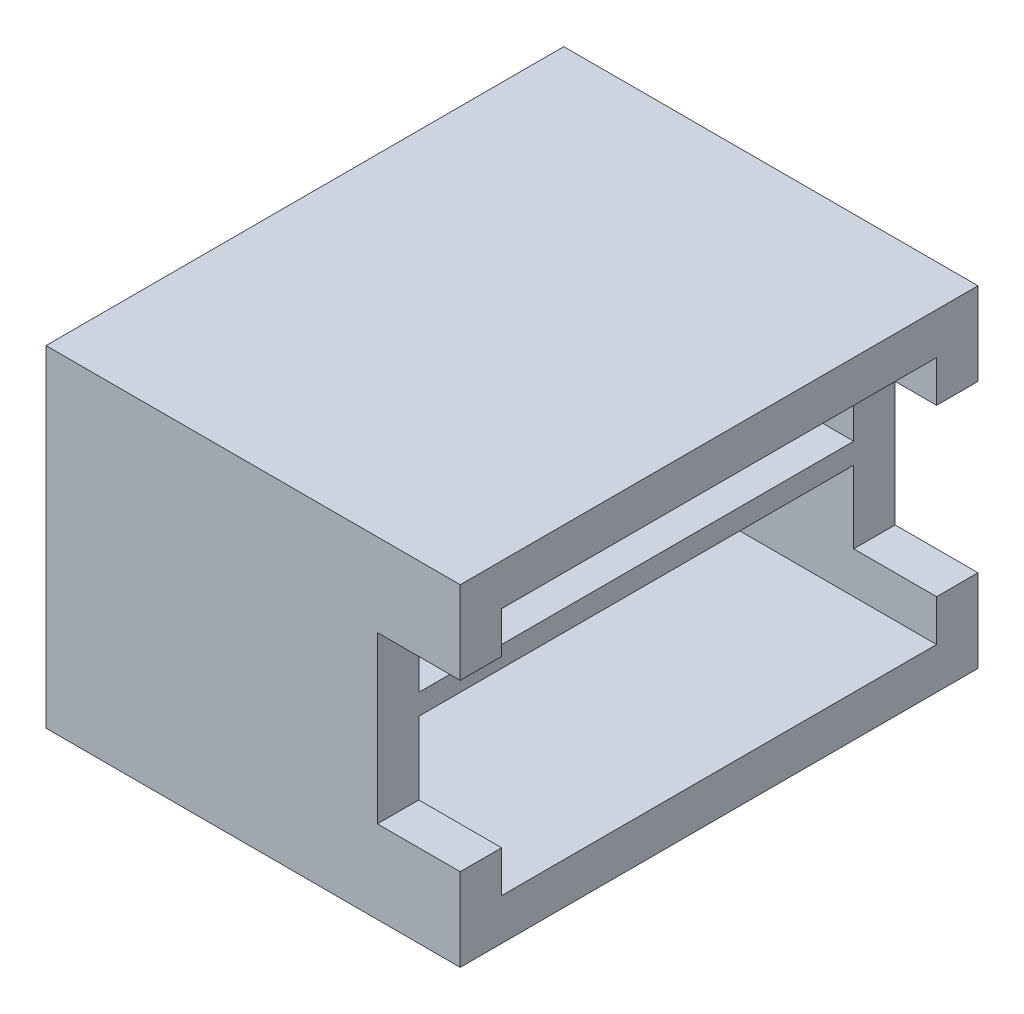
from build123d import *

# Parameters (mm, degrees)
CROQUIS1_W              = 20
CROQUIS1_H              = 25
SALIENTE_EXTRUIR4_DEPTH = 16
CORTAR_EXTRUIR1_START   = 10
CROQUIS4_W              = 21
CROQUIS4_H              = 12
CORTAR_EXTRUIR1_DEPTH   = 18
SALIENTE_EXTRUIR6_START = -10
CROQUIS5_W              = 21
CROQUIS5_H              = 1
SALIENTE_EXTRUIR6_DEPTH = 16
SALIENTE_EXTRUIR7_START = 10
CROQUIS7_W              = 2
CROQUIS7_H              = 8
SALIENTE_EXTRUIR7_DEPTH = 4
CORTAR_EXTRUIR2_START   = 14
CROQUIS7_2_W            = 2
CROQUIS7_2_H            = 8
CORTAR_EXTRUIR2_DEPTH   = 8
CROQUIS8_W              = 12.75
CROQUIS8_H              = 11
SALIENTE_EXTRUIR8_DEPTH = 3
CROQUIS9_W              = 9.75
CROQUIS9_H              = 1.5
CORTAR_EXTRUIR4_DEPTH   = 21.5


with BuildPart() as part:
    # Croquis1 → Saliente-Extruir4 (new body)
    with BuildSketch(Plane(origin=(0, 0, 0), x_dir=(1, 0, 0), z_dir=(0, 1, 0))):
        Rectangle(CROQUIS1_W, CROQUIS1_H)
    extrude(amount=SALIENTE_EXTRUIR4_DEPTH)

    # Croquis4 → Cortar-Extruir1 (cut)
    with BuildSketch(Plane(origin=(0, 0, 0), x_dir=(0, 0, -1), z_dir=(1, 0, 0)).offset(CORTAR_EXTRUIR1_START)):
        with Locations((0, 8)):
            Rectangle(CROQUIS4_W, CROQUIS4_H)
    extrude(amount=-CORTAR_EXTRUIR1_DEPTH, mode=Mode.SUBTRACT)

    # Croquis5 → Saliente-Extruir6 (add)
    with BuildSketch(Plane(origin=(0, 0, 0), x_dir=(0, 0, -1), z_dir=(1, 0, 0)).offset(SALIENTE_EXTRUIR6_START)):
        with Locations((0, 8)):
            Rectangle(CROQUIS5_W, CROQUIS5_H)
    extrude(amount=SALIENTE_EXTRUIR6_DEPTH)

    # Croquis7 → Saliente-Extruir7 (add)
    with BuildSketch(Plane(origin=(0, 0, 0), x_dir=(0, 0, -1), z_dir=(1, 0, 0)).offset(SALIENTE_EXTRUIR7_START)):
        with Locations((-11.5, 8)):
            Rectangle(CROQUIS7_W, CROQUIS7_H)
        with Locations((11.5, 8)):
            Rectangle(CROQUIS7_W, CROQUIS7_H)
    extrude(amount=SALIENTE_EXTRUIR7_DEPTH)

    # Croquis7_2 → Cortar-Extruir2 (cut)
    with BuildSketch(Plane(origin=(0, 0, 0), x_dir=(0, 0, -1), z_dir=(1, 0, 0)).offset(CORTAR_EXTRUIR2_START)):
        with Locations((-11.5, 8)):
            Rectangle(CROQUIS7_2_W, CROQUIS7_2_H)
        with Locations((11.5, 8)):
            Rectangle(CROQUIS7_2_W, CROQUIS7_2_H)
    extrude(amount=-CORTAR_EXTRUIR2_DEPTH, mode=Mode.SUBTRACT)

    # Croquis8 → Saliente-Extruir8 (add)
    with BuildSketch(Plane(origin=(0, 0, 0), x_dir=(1, 0, 0), z_dir=(0, 1, 0))):
        with Locations((-3.625, 0)):
            Rectangle(CROQUIS8_W, CROQUIS8_H)
    extrude(amount=-SALIENTE_EXTRUIR8_DEPTH)

    # Croquis9 → Cortar-Extruir4 (cut, symmetric)
    with BuildSketch(Plane.XY):
        with Locations((-3.625, -0.75)):
            Rectangle(CROQUIS9_W, CROQUIS9_H)
    extrude(amount=CORTAR_EXTRUIR4_DEPTH, both=True, mode=Mode.SUBTRACT)


solid = part.part
